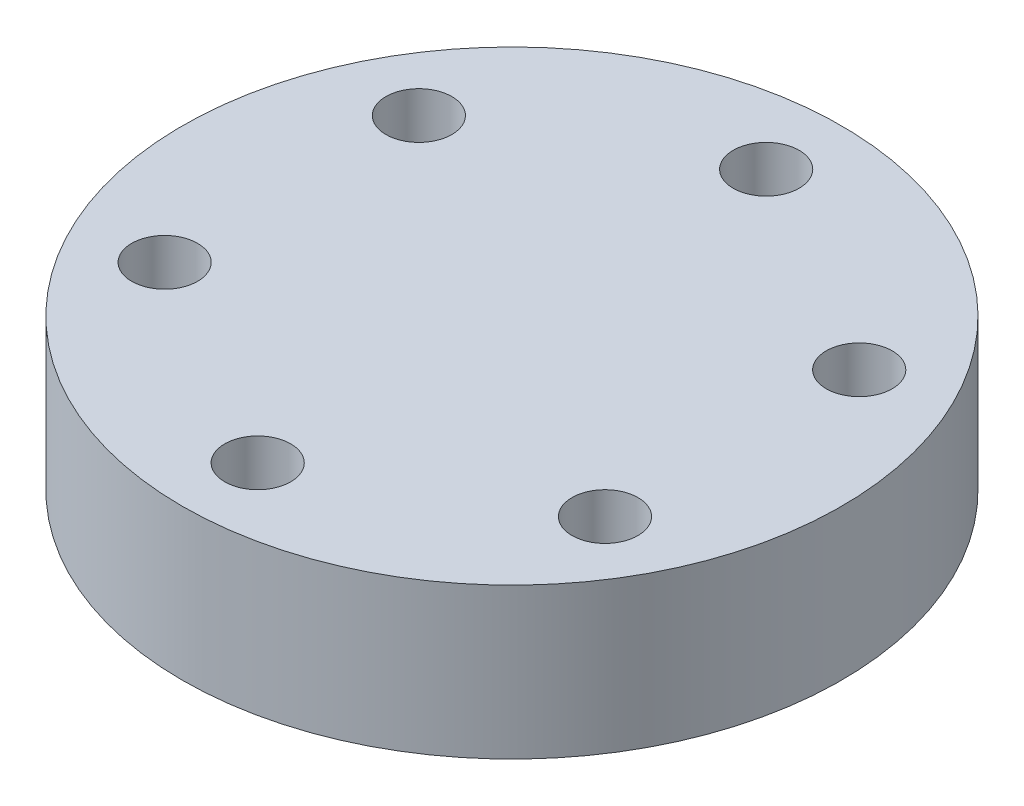
from build123d import *

# Parameters (mm, degrees)
SKETCH_1_R          = 17.5
EXTRUDE_1_DEPTH     = 8
SKETCH_2_R          = 1.75
CUT_EXTRUDE_1_DEPTH = 14


with BuildPart() as part:
    # 草图1 → 凸台-拉伸1 (new body)
    with BuildSketch(Plane(origin=(0, 0, 0), x_dir=(1, 0, 0), z_dir=(0, 1, 0))):
        Circle(SKETCH_1_R)
    extrude(amount=EXTRUDE_1_DEPTH)

    # 草图2 → 切除-拉伸1 (cut)
    with BuildSketch(Plane(origin=(0, 8, 0), x_dir=(1, 0, 0), z_dir=(0, 1, 0))):
        with Locations((0, 13.5)):
            Circle(SKETCH_2_R)
        with Locations((11.691342951, 6.75)):
            Circle(SKETCH_2_R)
        with Locations((11.691342951, -6.75)):
            Circle(SKETCH_2_R)
        with Locations((0, -13.5)):
            Circle(SKETCH_2_R)
        with Locations((-11.691342951, -6.75)):
            Circle(SKETCH_2_R)
        with Locations((-11.691342951, 6.75)):
            Circle(SKETCH_2_R)
    extrude(amount=-CUT_EXTRUDE_1_DEPTH, mode=Mode.SUBTRACT)


solid = part.part
